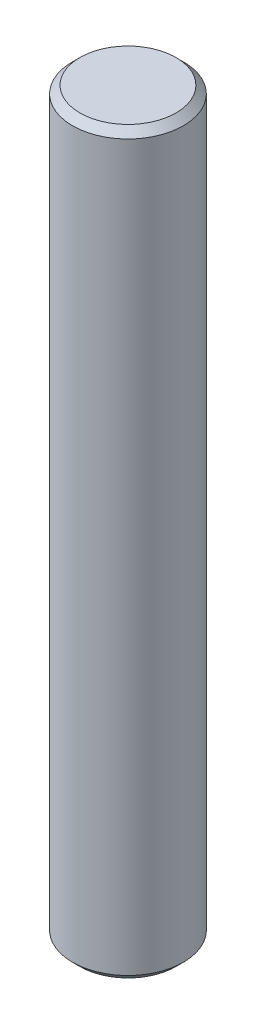
from build123d import *

# Parameters (mm, degrees)
ESQUISSE1_R      = 1.5
EXTRUSION1_DEPTH = 20
CHANFREIN1_SIZE  = 0.2


with BuildPart() as part:
    # Esquisse1 → Extrusion1 (new body)
    with BuildSketch(Plane(origin=(0, 0, 0), x_dir=(1, 0, 0), z_dir=(0, 1, 0))):
        with Locations(Location((0, 0, 0), (0, 0, 270))):  # turned: the seam where the file's is
            Circle(ESQUISSE1_R)
    extrude(amount=EXTRUSION1_DEPTH)

    # Chanfrein1
    chanfrein1_edges = [part.edges().sort_by_distance(p)[0] for p in [
        (0, 0, -1.5),
        (0, 20, -1.5),
    ]]
    chamfer(chanfrein1_edges, length=CHANFREIN1_SIZE)


solid = part.part
